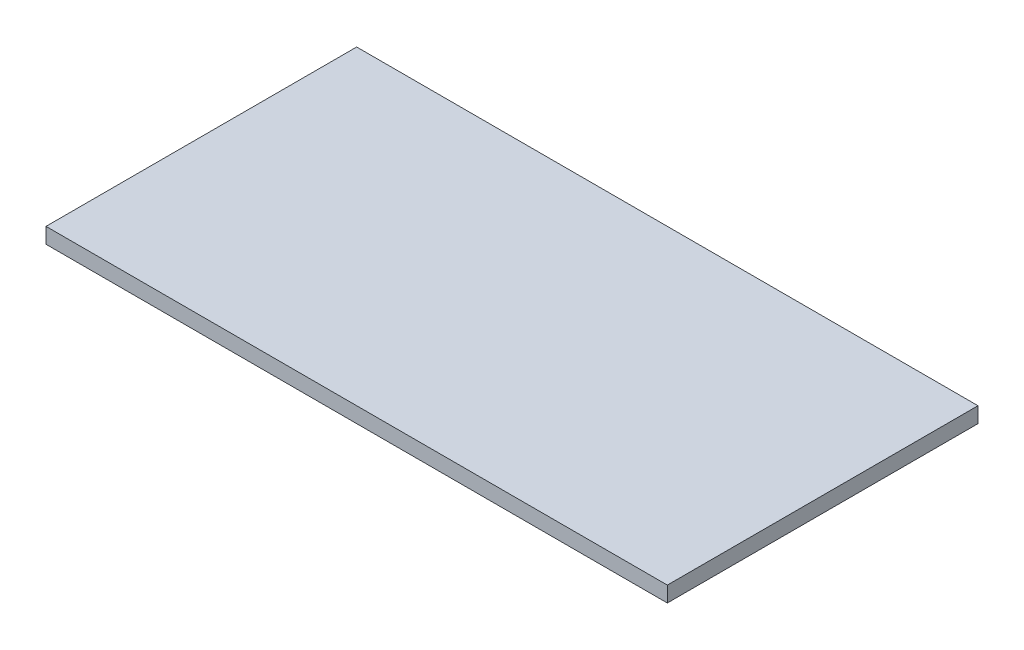
from build123d import *

# Parameters (mm, degrees)
SKETCH1_W           = 254
SKETCH1_H           = 127
BOSS_EXTRUDE1_DEPTH = 6.35


with BuildPart() as part:
    # Sketch1 → Boss-Extrude1 (new body)
    with BuildSketch(Plane(origin=(0, 0, 0), x_dir=(1, 0, 0), z_dir=(0, 1, 0))):
        Rectangle(SKETCH1_W, SKETCH1_H)
    extrude(amount=BOSS_EXTRUDE1_DEPTH)


solid = part.part
